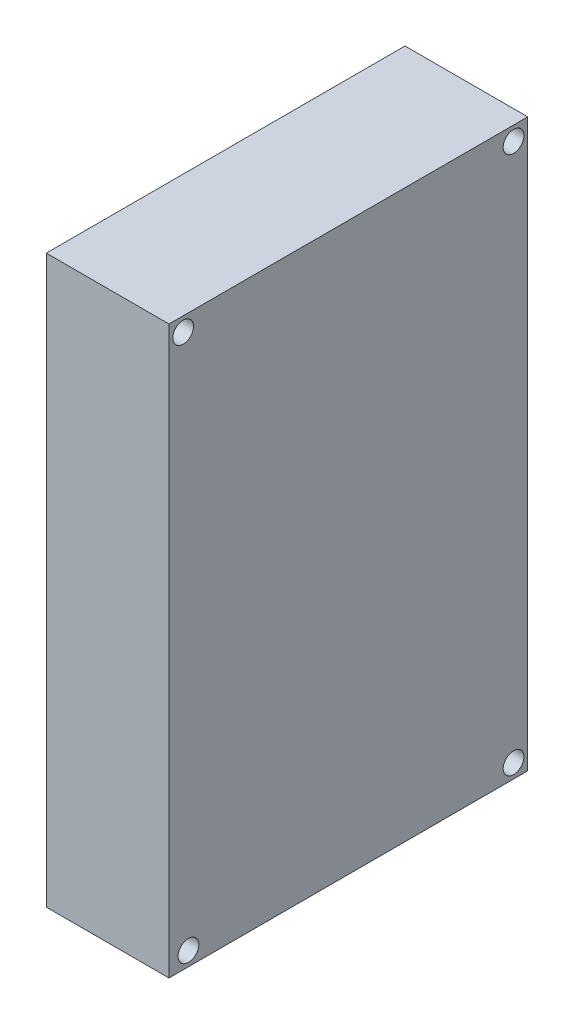
from build123d import *

# Parameters (mm, degrees)
SKETCH1_W           = 13
SKETCH1_H           = 60
BOSS_EXTRUDE1_DEPTH = 38
SKETCH2_R           = 1.1
CUT_EXTRUDE1_DEPTH  = 14


with BuildPart() as part:
    # Sketch1 → Boss-Extrude1 (new body)
    with BuildSketch(Plane.XY):
        Rectangle(SKETCH1_W, SKETCH1_H)
    extrude(amount=BOSS_EXTRUDE1_DEPTH)

    # Sketch2 → Cut-Extrude1 (cut, through all)
    with BuildSketch(Plane(origin=(6.5, 0, 0), x_dir=(0, 0, -1), z_dir=(1, 0, 0))):
        with Locations((-1.5, 28.497237598)):
            Circle(SKETCH2_R)
        with Locations((-36.5, 28.497237598)):
            Circle(SKETCH2_R)
        with Locations((-35.938834987, -28.5)):
            Circle(SKETCH2_R)
        with Locations((-1.5, -28.5)):
            Circle(SKETCH2_R)
    extrude(amount=-CUT_EXTRUDE1_DEPTH, mode=Mode.SUBTRACT)


solid = part.part
